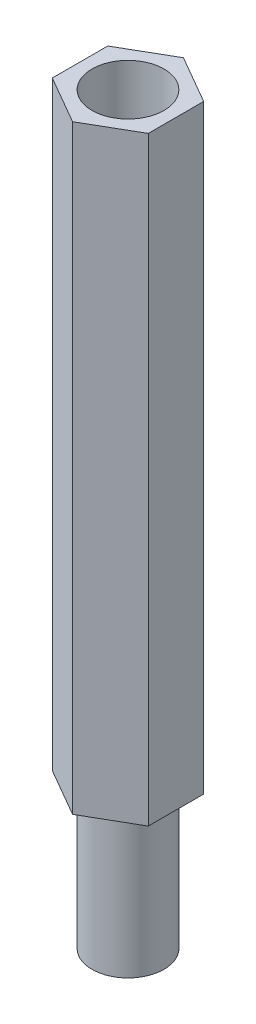
from build123d import *

# Parameters (mm, degrees)
BOSS_EXTRUDE1_DEPTH = 25
SKETCH2_R           = 1.5
CUT_EXTRUDE1_DEPTH  = 19
SKETCH3_R           = 1.5
BOSS_EXTRUDE2_DEPTH = 6


with BuildPart() as part:
    # Sketch1 → Boss-Extrude1 (new body)
    with BuildSketch(Plane(origin=(0, 0, 0), x_dir=(1, 0, 0), z_dir=(0, 1, 0))):
        Polygon((0, -2.309401077), (2, -1.154700538), (2, 1.154700538), (0, 2.309401077), (-2, 1.154700538), (-2, -1.154700538), align=None)
    extrude(amount=BOSS_EXTRUDE1_DEPTH)

    # Sketch2 → Cut-Extrude1 (cut)
    with BuildSketch(Plane(origin=(0, 25, 0), x_dir=(1, 0, 0), z_dir=(0, 1, 0))):
        Circle(SKETCH2_R)
    extrude(amount=-CUT_EXTRUDE1_DEPTH, mode=Mode.SUBTRACT)

    # Sketch3 → Boss-Extrude2 (add)
    with BuildSketch(Plane.XZ):
        Circle(SKETCH3_R)
    extrude(amount=BOSS_EXTRUDE2_DEPTH)


solid = part.part
